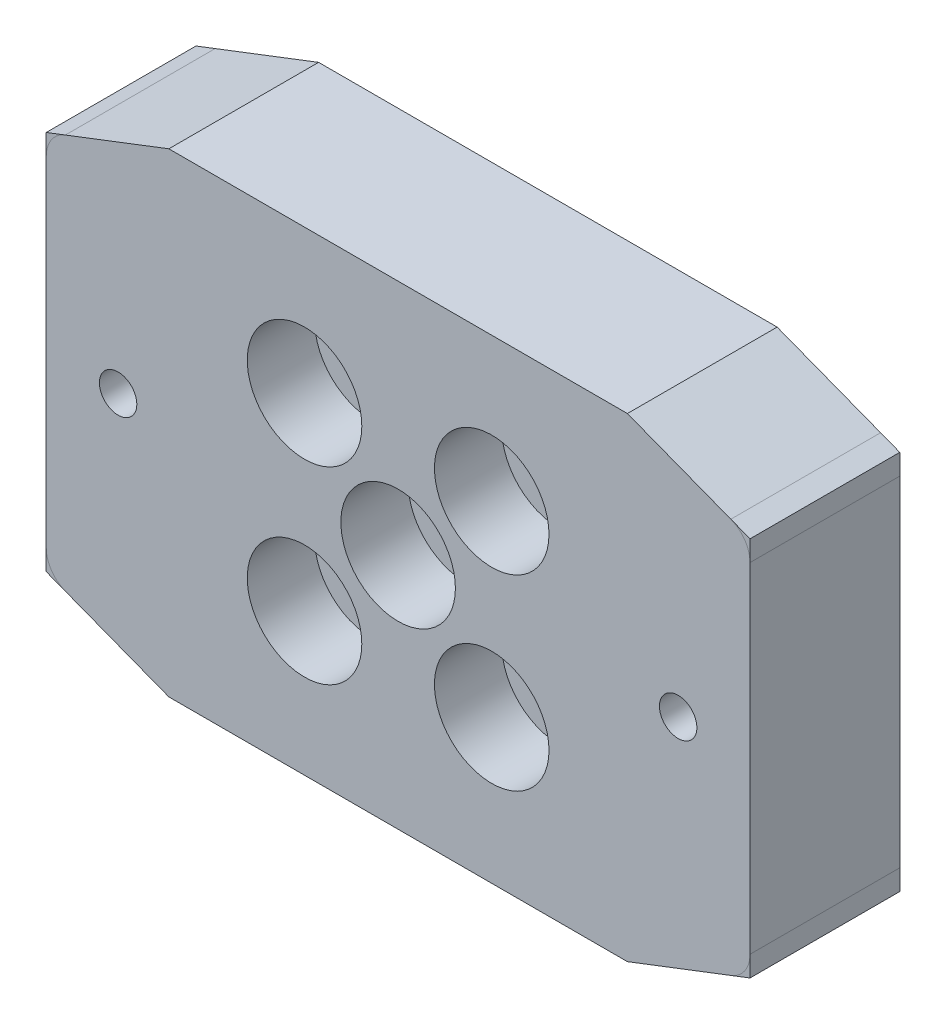
from build123d import *

# Parameters (mm, degrees)
SKETCH1_R             = 1.25
SKETCH1_R_2           = 2.25
BOSS_EXTRUDE1_DEPTH   = 10
SKETCH2_R             = 3.825
CUT_EXTRUDE1_DEPTH    = 4.5
CUT_EXTRUDE2_DEPTH    = 10
FILLET1_R             = 2
CUT_EXTRUDE3_DEPTH    = 10
CUT_EXTRUDE4_DEPTH    = 10
CUT_EXTRUDE6_DEPTH    = 10
BOSS_EXTRUDE2_DEPTH   = 10
BOSS_EXTRUDE2_2_DEPTH = 10
BOSS_EXTRUDE2_3_DEPTH = 10
BOSS_EXTRUDE2_4_DEPTH = 10


with BuildPart() as part:
    # Sketch1 → Boss-Extrude1 (new body)
    with BuildSketch(Plane.XY):
        Polygon((-12.7, 23.5), (12.7, 23.5), (23.5, 12.7), (23.5, -12.7), (12.7, -23.5), (-12.7, -23.5), (-23.5, -12.7), (-23.5, 12.7), align=None)
        with Locations((0, 18.7)):
            Circle(SKETCH1_R, mode=Mode.SUBTRACT)
        with Locations((18.7, 0)):
            Circle(SKETCH1_R, mode=Mode.SUBTRACT)
        with Locations((0, -18.7)):
            Circle(SKETCH1_R, mode=Mode.SUBTRACT)
        with Locations((-18.7, 0)):
            Circle(SKETCH1_R, mode=Mode.SUBTRACT)
        Circle(SKETCH1_R_2, mode=Mode.SUBTRACT)
        with Locations((-6.25, 6.25)):
            Circle(SKETCH1_R_2, mode=Mode.SUBTRACT)
        with Locations((6.25, 6.25)):
            Circle(SKETCH1_R_2, mode=Mode.SUBTRACT)
        with Locations((6.25, -6.25)):
            Circle(SKETCH1_R_2, mode=Mode.SUBTRACT)
        with Locations((-6.25, -6.35)):
            Circle(SKETCH1_R_2, mode=Mode.SUBTRACT)
    extrude(amount=BOSS_EXTRUDE1_DEPTH)

    # Sketch2 → Cut-Extrude1 (cut)
    with BuildSketch(Plane.XY.offset(10)):
        with Locations((-6.25, 6.25)):
            Circle(SKETCH2_R)
        with Locations((6.25, 6.25)):
            Circle(SKETCH2_R)
        Circle(SKETCH2_R)
        with Locations((-6.25, -6.35)):
            Circle(SKETCH2_R)
        with Locations((6.25, -6.25)):
            Circle(SKETCH2_R)
    extrude(amount=-CUT_EXTRUDE1_DEPTH, mode=Mode.SUBTRACT)

    # Sketch3 → Cut-Extrude2 (cut)
    with BuildSketch(Plane.XY.offset(10)):
        Polygon((12.7, 23.5), (15.7, 15.7), (23.5, 12.7), align=None)
        Polygon((23.5, -12.7), (15.7, -15.7), (12.7, -23.5), align=None)
        Polygon((-12.7, -23.5), (-15.7, -15.7), (-23.5, -12.7), align=None)
        Polygon((-23.5, 12.7), (-15.7, 15.7), (-12.7, 23.5), align=None)
    extrude(amount=-CUT_EXTRUDE2_DEPTH, mode=Mode.SUBTRACT)

    # Fillet1
    fillet1_edges = [part.edges().sort_by_distance(p)[0] for p in [
        (15.7, 15.7, 5),
        (15.7, -15.7, 5),
        (-15.7, -15.7, 5),
        (-23.5, -12.7, 5),
        (-23.5, 12.7, 5),
        (-12.7, 23.5, 5),
        (12.7, 23.5, 5),
        (23.5, 12.7, 5),
        (23.5, -12.7, 5),
        (12.7, -23.5, 5),
        (-12.7, -23.5, 5),
        (-15.7, 15.7, 5),
    ]]
    fillet(fillet1_edges, radius=FILLET1_R)

    # Sketch5 → Cut-Extrude3 (cut)
    with BuildSketch(Plane.XY.offset(10)):
        with BuildLine():
            Line((-15.788258503, 15.88), (15.788258503, 15.88))
            ThreePointArc((15.788258503, 15.88), (15.553157953, 16.185115491), (15.380907485, 16.529640539))
            Line((15.380907485, 16.529640539), (13.193093016, 22.217958159))
            ThreePointArc((13.193093016, 22.217958159), (12.458674669, 23.14862311), (11.326401804, 23.5))
            Line((11.326401804, 23.5), (-11.326401804, 23.5))
            ThreePointArc((-11.326401804, 23.5), (-12.458674669, 23.14862311), (-13.193093016, 22.217958159))
            Line((-13.193093016, 22.217958159), (-15.380907485, 16.529640539))
            ThreePointArc((-15.380907485, 16.529640539), (-15.553157953, 16.185115491), (-15.788258503, 15.88))
        make_face()
        with BuildLine():
            Line((-15.788258503, -15.88), (15.788258503, -15.88))
            ThreePointArc((15.788258503, -15.88), (15.553157953, -16.185115491), (15.380907485, -16.529640539))
            Line((15.380907485, -16.529640539), (13.193093016, -22.217958159))
            ThreePointArc((13.193093016, -22.217958159), (12.458674669, -23.14862311), (11.326401804, -23.5))
            Line((11.326401804, -23.5), (-11.326401804, -23.5))
            ThreePointArc((-11.326401804, -23.5), (-12.458674669, -23.14862311), (-13.193093016, -22.217958159))
            Line((-13.193093016, -22.217958159), (-15.380907485, -16.529640539))
            ThreePointArc((-15.380907485, -16.529640539), (-15.553157953, -16.185115491), (-15.788258503, -15.88))
        make_face()
    extrude(amount=-CUT_EXTRUDE3_DEPTH, mode=Mode.SUBTRACT)

    # Sketch6 → Cut-Extrude4 (cut)
    with BuildSketch(Plane.XY.offset(10)):
        with BuildLine():
            Line((-16.529640539, -15.380907485), (-15.232, -15.88))
            Line((-15.232, -15.88), (-15.788258503, -15.88))
            ThreePointArc((-15.788258503, -15.88), (-16.130714476, -15.588511709), (-16.529640539, -15.380907485))
        make_face()
        with BuildLine():
            Line((15.788258503, -15.88), (15.232, -15.88))
            Line((15.232, -15.88), (16.529640539, -15.380907485))
            ThreePointArc((16.529640539, -15.380907485), (16.130714476, -15.588511709), (15.788258503, -15.88))
        make_face()
        with BuildLine():
            Line((16.529640539, 15.380907485), (15.232, 15.88))
            Line((15.232, 15.88), (15.788258503, 15.88))
            ThreePointArc((15.788258503, 15.88), (16.130714476, 15.588511709), (16.529640539, 15.380907485))
        make_face()
        with BuildLine():
            Line((-15.788258503, 15.88), (-15.232, 15.88))
            Line((-15.232, 15.88), (-16.529640539, 15.380907485))
            ThreePointArc((-16.529640539, 15.380907485), (-16.130714476, 15.588511709), (-15.788258503, 15.88))
        make_face()
    extrude(amount=-CUT_EXTRUDE4_DEPTH, mode=Mode.SUBTRACT)

    # Sketch7 → Cut-Extrude6 (cut)
    with BuildSketch(Plane.XY.offset(10)):
        Polygon((-15.31, 15.85), (15.31, 15.85), (15.232, 15.88), (-15.232, 15.88), align=None)
        Polygon((-15.31, -15.85), (15.31, -15.85), (15.232, -15.88), (-15.232, -15.88), align=None)
    extrude(amount=-CUT_EXTRUDE6_DEPTH, mode=Mode.SUBTRACT)


with BuildPart() as body_2:
    # Sketch8 → Boss-Extrude2 (new body)
    with BuildSketch(Plane.XY.offset(10)):
        with BuildLine():
            Line((-23.5, -11.326401804), (-23.5, -12.7))
            Line((-23.5, -12.7), (-22.217958159, -13.193093016))
            ThreePointArc((-22.217958159, -13.193093016), (-23.14862311, -12.458674669), (-23.5, -11.326401804))
        make_face()
    extrude(amount=-BOSS_EXTRUDE2_DEPTH)


with BuildPart() as body_3:
    # Sketch8 → Boss-Extrude2 2 (new body)
    with BuildSketch(Plane.XY.offset(10)):
        with BuildLine():
            Line((23.5, 11.326401804), (23.5, 12.7))
            Line((23.5, 12.7), (22.217958159, 13.193093016))
            ThreePointArc((22.217958159, 13.193093016), (23.14862311, 12.458674669), (23.5, 11.326401804))
        make_face()
    extrude(amount=-BOSS_EXTRUDE2_2_DEPTH)


with BuildPart() as body_4:
    # Sketch8 → Boss-Extrude2 3 (new body)
    with BuildSketch(Plane.XY.offset(10)):
        with BuildLine():
            Line((-22.217958159, 13.193093016), (-23.5, 12.7))
            Line((-23.5, 12.7), (-23.5, 11.326401804))
            ThreePointArc((-23.5, 11.326401804), (-23.14862311, 12.458674669), (-22.217958159, 13.193093016))
        make_face()
    extrude(amount=-BOSS_EXTRUDE2_3_DEPTH)


with BuildPart() as body_5:
    # Sketch8 → Boss-Extrude2 4 (new body)
    with BuildSketch(Plane.XY.offset(10)):
        with BuildLine():
            Line((22.217958159, -13.193093016), (23.5, -12.7))
            Line((23.5, -12.7), (23.5, -11.326401804))
            ThreePointArc((23.5, -11.326401804), (23.14862311, -12.458674669), (22.217958159, -13.193093016))
        make_face()
    extrude(amount=-BOSS_EXTRUDE2_4_DEPTH)


solid = Compound([part.part, body_2.part, body_3.part, body_4.part, body_5.part])
